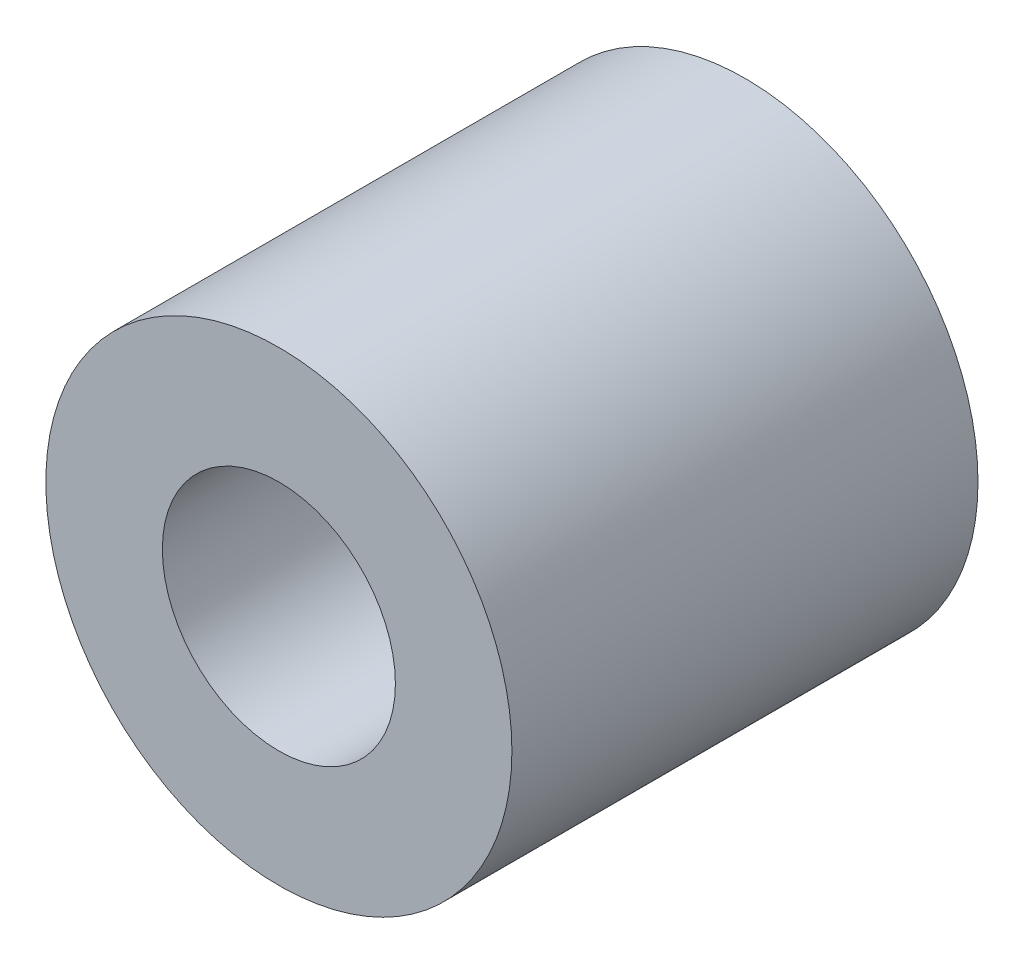
from build123d import *

# Parameters (mm, degrees)
SKETCH1_R           = 12.7
BOSS_EXTRUDE1_DEPTH = 25.4
SKETCH2_R           = 6.35
CUT_EXTRUDE1_DEPTH  = 25.4


with BuildPart() as part:
    # Sketch1 → Boss-Extrude1 (new body)
    with BuildSketch(Plane.XY):
        Circle(SKETCH1_R)
    extrude(amount=BOSS_EXTRUDE1_DEPTH)

    # Sketch2 → Cut-Extrude1 (cut)
    with BuildSketch(Plane.XY.offset(25.4)):
        Circle(SKETCH2_R)
    extrude(amount=-CUT_EXTRUDE1_DEPTH, mode=Mode.SUBTRACT)


solid = part.part
